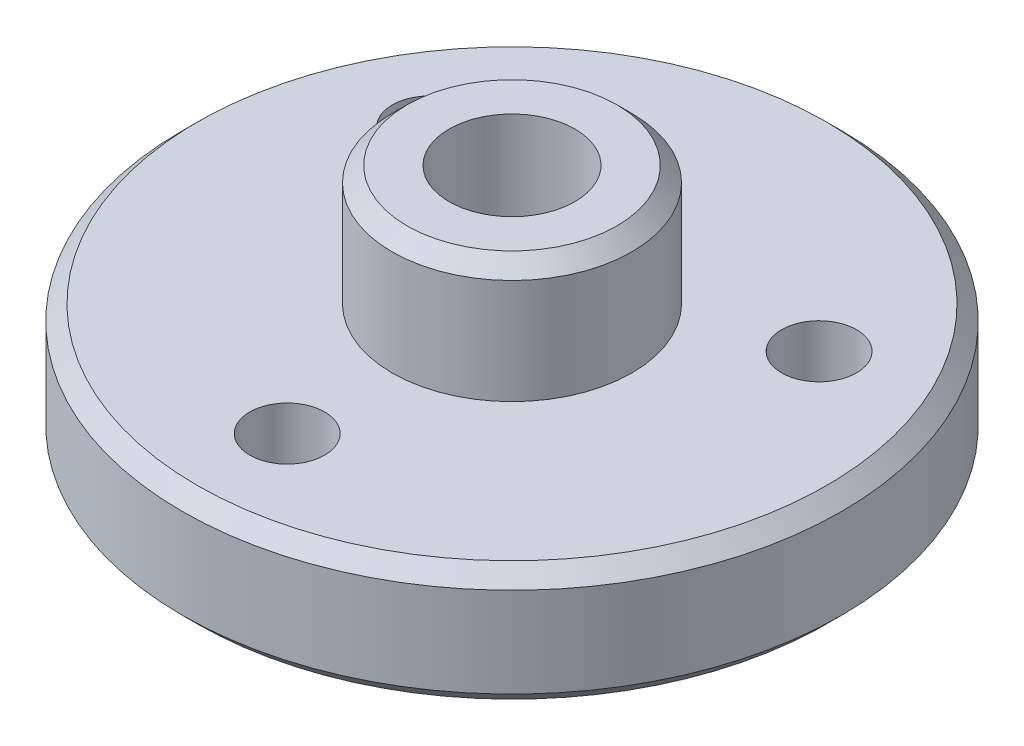
from build123d import *

# Parameters (mm, degrees)
HOLE_WIZARD_M3_1_D = 2.5
HOLE_WIZARD_M5_1_D = 4.2
CHAMFER_1_SIZE     = 0.5


with BuildPart() as part:
    # 草图1 → 旋转1 (revolve)
    with BuildSketch(Plane.XY):
        Polygon((0, 8), (0, 0), (3, 0), (3, -0.9), (4, -0.9), (4, 0), (11, 0), (11, 4), (4, 4), (4, 8), align=None)
    revolve(axis=Axis((0, 0, 0), (0, -1, 0)))

    # M3 螺纹孔1 (through all)
    with Locations(Plane(origin=(0, 4, 0), x_dir=(1, 0, 0), z_dir=(0, 1, 0))):
        with Locations((-6.495190528, 3.75), (6.495190528, 3.75), (0, -7.5)):
            Hole(HOLE_WIZARD_M3_1_D / 2)

    # M5 螺纹孔1 (through all)
    with Locations(Plane(origin=(0, 0, 0), x_dir=(-1, 0, 0), z_dir=(0, -1, 0))):
        with Locations((0, 0)):
            Hole(HOLE_WIZARD_M5_1_D / 2)

    # 倒角1
    chamfer_1_edges = [part.edges().sort_by_distance(p)[0] for p in [
        (-4, 8, 0),
        (-11, 4, 0),
        (-11, 0, 0),
        (-4, 0, 0),
    ]]
    chamfer(chamfer_1_edges, length=CHAMFER_1_SIZE)


solid = part.part
